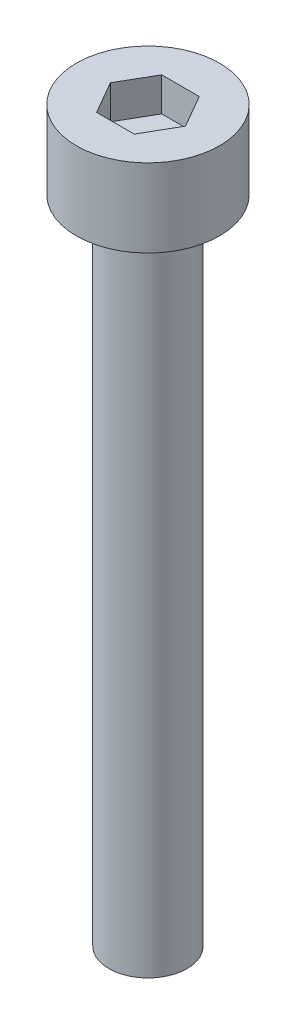
from build123d import *

# Parameters (mm, degrees)
SKETCH_1_R            = 2.75
EXTRUDE_248_DEPTH     = 3
CUT_EXTRUDE_378_DEPTH = 1.3
SKETCH_3_R            = 1.5
EXTRUDE_479_DEPTH     = 25


with BuildPart() as part:
    # 草图1 → Extrude 248 (new body)
    with BuildSketch(Plane(origin=(0, 0, 0), x_dir=(1, 0, 0), z_dir=(0, 1, 0))):
        Circle(SKETCH_1_R)
    extrude(amount=EXTRUDE_248_DEPTH)

    # 草图2 → Cut-Extrude 378 (cut)
    with BuildSketch(Plane(origin=(0, 3, 0), x_dir=(1, 0, 0), z_dir=(0, 1, 0))):
        Polygon((1.443375673, 0), (0.721687836, 1.25), (-0.721687836, 1.25), (-1.443375673, 0), (-0.721687836, -1.25), (0.721687836, -1.25), align=None)
    extrude(amount=-CUT_EXTRUDE_378_DEPTH, mode=Mode.SUBTRACT)

    # 草图3 → Extrude 479 (add)
    with BuildSketch(Plane.XZ):
        Circle(SKETCH_3_R)
    extrude(amount=EXTRUDE_479_DEPTH)


solid = part.part
